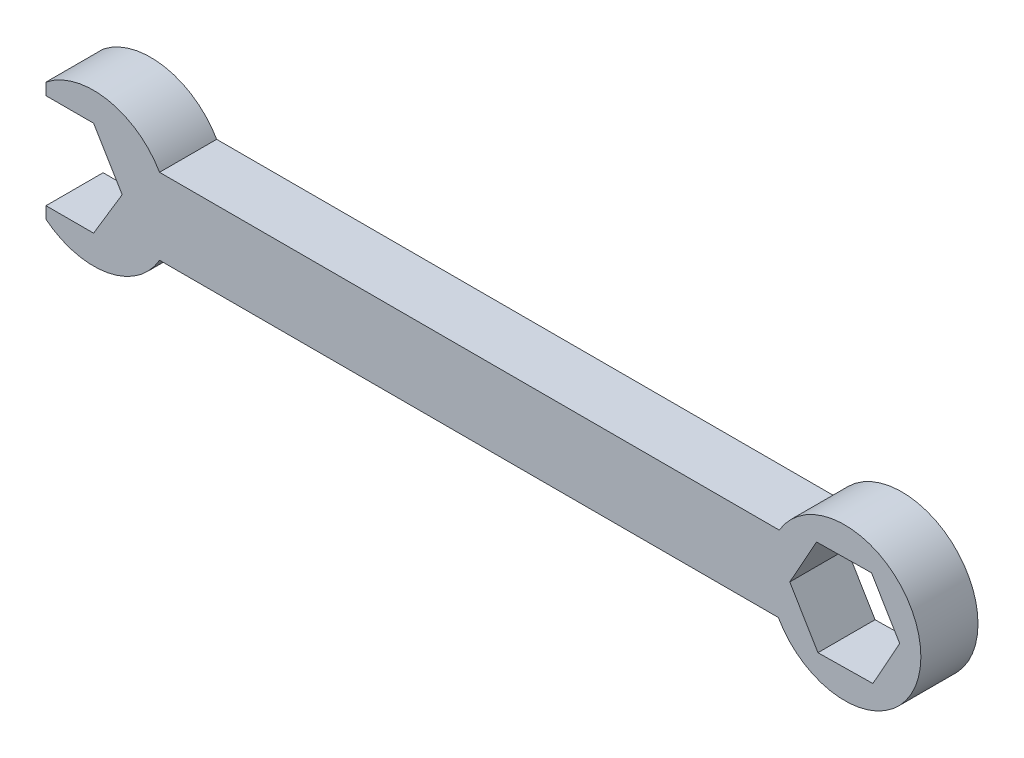
from build123d import *

# Parameters (mm, degrees)
BOSS_EXTRUDE2_DEPTH = 7.62


with BuildPart() as part:
    # Sketch3 → Boss-Extrude2 (new body)
    with BuildSketch(Plane.XY):
        with BuildLine():
            Line((-10.16, 6.35), (-3.81, 6.35))
            Line((-3.81, 6.35), (0, 0))
            Line((0, 0), (-3.81, -6.35))
            Line((-3.81, -6.35), (-10.16, -6.35))
            Line((-10.16, -6.35), (-10.16, -7.931147458))
            ThreePointArc((-10.16, -7.931147458), (-1.930787936, -9.984696391), (4.988818102, -5.08))
            Line((4.988818102, -5.08), (87.538818102, -5.08))
            ThreePointArc((87.538818102, -5.08), (106.555699626, -0.222294413), (87.657954776, 5.08))
            Line((87.657954776, 5.08), (4.988818102, 5.08))
            ThreePointArc((4.988818102, 5.08), (-1.930787936, 9.984696391), (-10.16, 7.931147458))
            Line((-10.16, 7.931147458), (-10.16, 6.35))
        make_face()
        Polygon((100.153044825, -6.400065038), (103.727996034, 0.001736052), (99.971349264, 6.298635161), (92.639751286, 6.19373318), (89.064800078, -0.20806791), (92.821446847, -6.504967018), align=None, mode=Mode.SUBTRACT)
    extrude(amount=BOSS_EXTRUDE2_DEPTH)


solid = part.part
